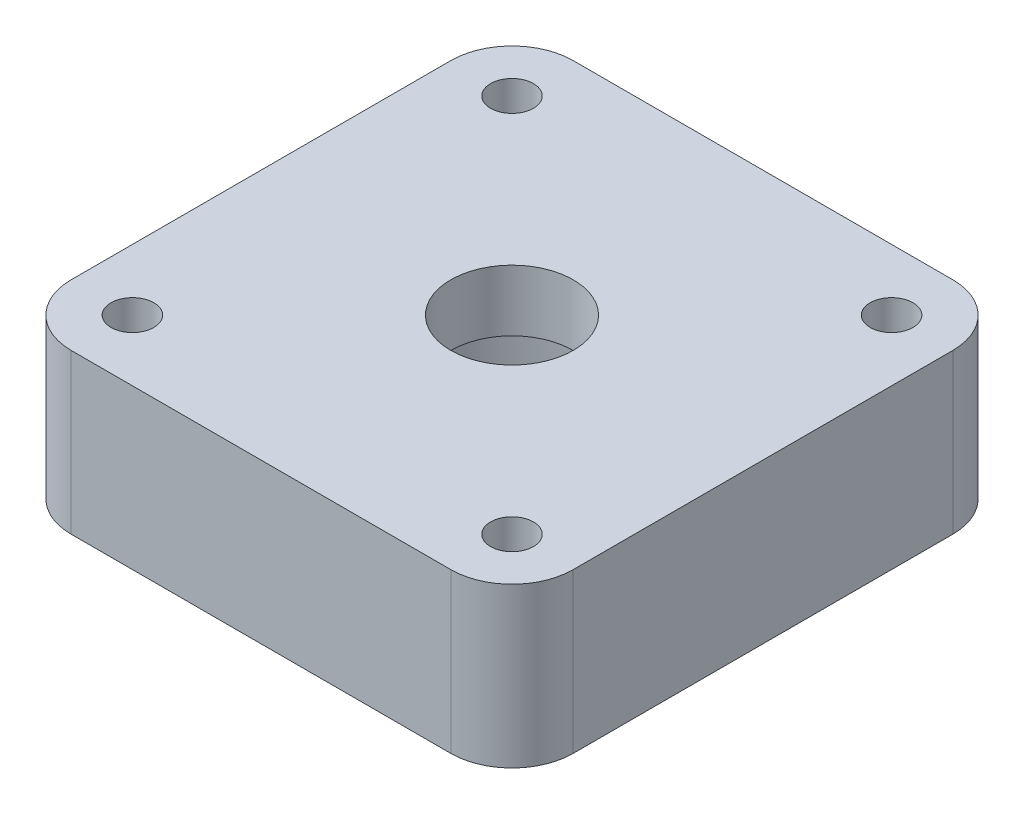
from build123d import *

# Parameters (mm, degrees)
SKETCH1_R           = 11
SKETCH1_R_2         = 1.75
BOSS_EXTRUDE1_DEPTH = 8
SKETCH2_R           = 1.75
SKETCH2_R_2         = 5
BOSS_EXTRUDE2_DEPTH = 5
CUT_EXTRUDE1_DEPTH  = 3


with BuildPart() as part:
    # Sketch1 → Boss-Extrude1 (new body)
    with BuildSketch(Plane(origin=(0, 0, 0), x_dir=(1, 0, 0), z_dir=(0, 1, 0))):
        with BuildLine():
            Line((-15.5, 20.5), (15.5, 20.5))
            ThreePointArc((15.5, 20.5), (19.035533906, 19.035533906), (20.5, 15.5))
            Line((20.5, 15.5), (20.5, -15.5))
            ThreePointArc((20.5, -15.5), (19.035533906, -19.035533906), (15.5, -20.5))
            Line((15.5, -20.5), (-15.5, -20.5))
            ThreePointArc((-15.5, -20.5), (-19.035533906, -19.035533906), (-20.5, -15.5))
            Line((-20.5, -15.5), (-20.5, 15.5))
            ThreePointArc((-20.5, 15.5), (-19.035533906, 19.035533906), (-15.5, 20.5))
        make_face()
        Circle(SKETCH1_R, mode=Mode.SUBTRACT)
        with Locations((-15.5, 15.5)):
            Circle(SKETCH1_R_2, mode=Mode.SUBTRACT)
        with Locations((15.5, 15.5)):
            Circle(SKETCH1_R_2, mode=Mode.SUBTRACT)
        with Locations((15.5, -15.5)):
            Circle(SKETCH1_R_2, mode=Mode.SUBTRACT)
        with Locations((-15.5, -15.5)):
            Circle(SKETCH1_R_2, mode=Mode.SUBTRACT)
    extrude(amount=BOSS_EXTRUDE1_DEPTH)

    # Sketch2 → Boss-Extrude2 (add)
    with BuildSketch(Plane(origin=(0, 8, 0), x_dir=(1, 0, 0), z_dir=(0, 1, 0))):
        with BuildLine():
            Line((-20.5, 15.5), (-20.5, -15.5))
            ThreePointArc((-20.5, -15.5), (-19.035533906, -19.035533906), (-15.5, -20.5))
            Line((-15.5, -20.5), (15.5, -20.5))
            ThreePointArc((15.5, -20.5), (19.035533906, -19.035533906), (20.5, -15.5))
            Line((20.5, -15.5), (20.5, 15.5))
            ThreePointArc((20.5, 15.5), (19.035533906, 19.035533906), (15.5, 20.5))
            Line((15.5, 20.5), (-15.5, 20.5))
            ThreePointArc((-15.5, 20.5), (-19.035533906, 19.035533906), (-20.5, 15.5))
        make_face()
        with Locations((15.5, 15.5)):
            Circle(SKETCH2_R, mode=Mode.SUBTRACT)
        with Locations((15.5, -15.5)):
            Circle(SKETCH2_R, mode=Mode.SUBTRACT)
        with Locations((-15.5, 15.5)):
            Circle(SKETCH2_R, mode=Mode.SUBTRACT)
        Circle(SKETCH2_R_2, mode=Mode.SUBTRACT)
        with Locations((-15.5, -15.5)):
            Circle(SKETCH2_R, mode=Mode.SUBTRACT)
    extrude(amount=BOSS_EXTRUDE2_DEPTH)

    # Sketch3 → Cut-Extrude1 (cut)
    with BuildSketch(Plane.XZ):
        Polygon((-13.860691665, 18.219559066), (-17.035553071, 18.279462196), (-18.674861406, 15.55990313), (-17.139308335, 12.780440934), (-13.964446929, 12.720537804), (-12.325138594, 15.44009687), align=None)
        Polygon((12.325138594, 15.55990313), (13.860691665, 12.780440934), (17.035553071, 12.720537804), (18.674861406, 15.44009687), (17.139308335, 18.219559066), (13.964446929, 18.279462196), align=None)
        Polygon((13.964446929, -12.720537804), (12.325138594, -15.44009687), (13.860691665, -18.219559066), (17.035553071, -18.279462196), (18.674861406, -15.55990313), (17.139308335, -12.780440934), align=None)
        Polygon((-13.860691665, -12.780440934), (-17.035553071, -12.720537804), (-18.674861406, -15.44009687), (-17.139308335, -18.219559066), (-13.964446929, -18.279462196), (-12.325138594, -15.55990313), align=None)
    extrude(amount=-CUT_EXTRUDE1_DEPTH, mode=Mode.SUBTRACT)


solid = part.part
